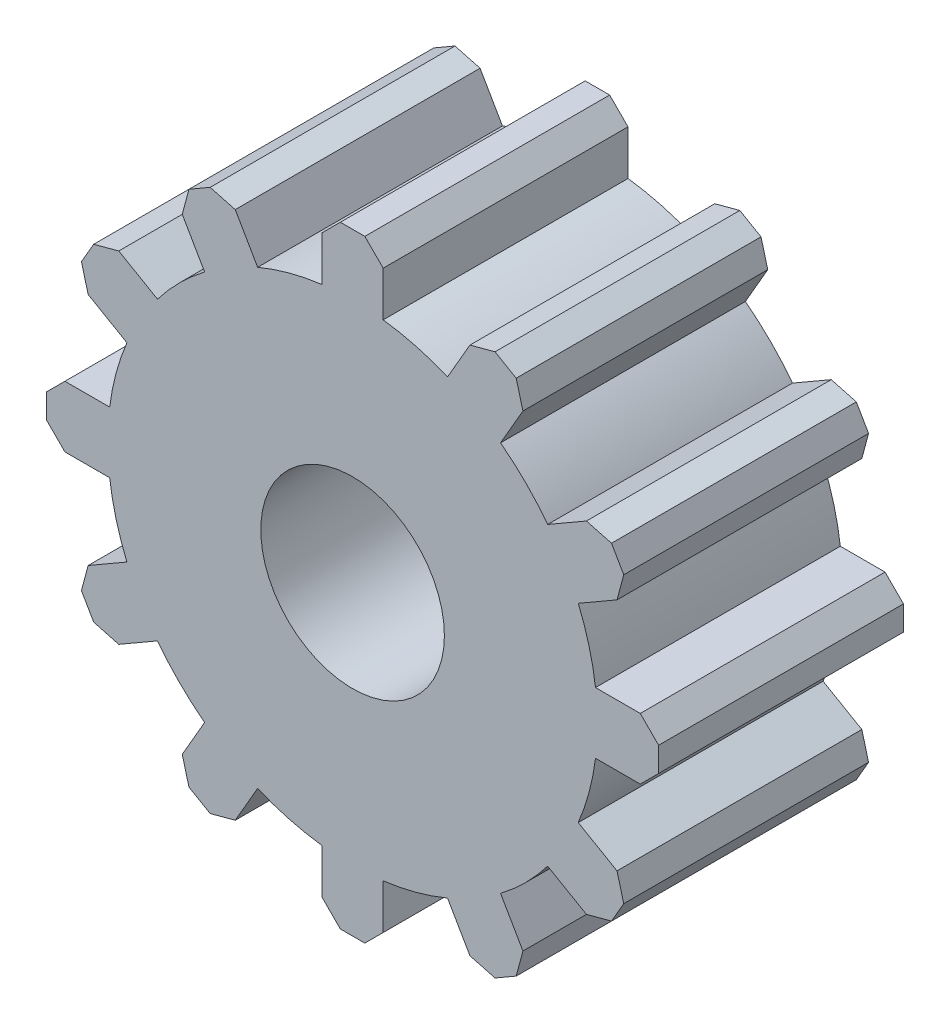
from build123d import *

# Parameters (mm, degrees)
SKETCH1_R           = 101.6
BOSS_EXTRUDE1_DEPTH = 50.8
BOSS_EXTRUDE2_DEPTH = 101.6
CHAMFER1_SIZE       = 7.62
SKETCH3_R           = 38.1
CUT_EXTRUDE1_DEPTH  = 102.6


with BuildPart() as part:
    # Sketch1 → Boss-Extrude1 (new body, symmetric)
    with BuildSketch(Plane.XY):
        Circle(SKETCH1_R)
    extrude(amount=BOSS_EXTRUDE1_DEPTH, both=True)

    # Sketch2 → Boss-Extrude2 (add, through all)
    with BuildSketch(Plane.XY.offset(50.8)):
        with BuildLine():
            Line((74.498522628, 103.635226281), (52.501477372, 116.335226281))
            Line((52.501477372, 116.335226281), (39.403039848, 93.648066989))
            ThreePointArc((39.403039848, 93.648066989), (50.8, 87.988181024), (61.400085104, 80.948066989))
            Line((61.400085104, 80.948066989), (74.498522628, 103.635226281))
        make_face()
        with BuildLine():
            Line((12.7, 100.803124952), (12.7, 127))
            Line((12.7, 127), (-12.7, 127))
            Line((-12.7, 127), (-12.7, 100.803124952))
            ThreePointArc((-12.7, 100.803124952), (0, 101.6), (12.7, 100.803124952))
        make_face()
        with BuildLine():
            Line((116.335226281, 52.501477372), (103.635226281, 74.498522628))
            Line((103.635226281, 74.498522628), (80.948066989, 61.400085104))
            ThreePointArc((80.948066989, 61.400085104), (87.988181024, 50.8), (93.648066989, 39.403039848))
            Line((93.648066989, 39.403039848), (116.335226281, 52.501477372))
        make_face()
        with BuildLine():
            Line((127, -12.7), (127, 12.7))
            Line((127, 12.7), (100.803124952, 12.7))
            ThreePointArc((100.803124952, 12.7), (101.6, 0), (100.803124952, -12.7))
            Line((100.803124952, -12.7), (127, -12.7))
        make_face()
        with BuildLine():
            Line((103.635226281, -74.498522628), (116.335226281, -52.501477372))
            Line((116.335226281, -52.501477372), (93.648066989, -39.403039848))
            ThreePointArc((93.648066989, -39.403039848), (87.988181024, -50.8), (80.948066989, -61.400085104))
            Line((80.948066989, -61.400085104), (103.635226281, -74.498522628))
        make_face()
        with BuildLine():
            Line((52.501477372, -116.335226281), (74.498522628, -103.635226281))
            Line((74.498522628, -103.635226281), (61.400085104, -80.948066989))
            ThreePointArc((61.400085104, -80.948066989), (50.8, -87.988181024), (39.403039848, -93.648066989))
            Line((39.403039848, -93.648066989), (52.501477372, -116.335226281))
        make_face()
        with BuildLine():
            Line((-12.7, -127), (12.7, -127))
            Line((12.7, -127), (12.7, -100.803124952))
            ThreePointArc((12.7, -100.803124952), (0, -101.6), (-12.7, -100.803124952))
            Line((-12.7, -100.803124952), (-12.7, -127))
        make_face()
        with BuildLine():
            Line((-74.498522628, -103.635226281), (-52.501477372, -116.335226281))
            Line((-52.501477372, -116.335226281), (-39.403039848, -93.648066989))
            ThreePointArc((-39.403039848, -93.648066989), (-50.8, -87.988181024), (-61.400085104, -80.948066989))
            Line((-61.400085104, -80.948066989), (-74.498522628, -103.635226281))
        make_face()
        with BuildLine():
            Line((-116.335226281, -52.501477372), (-103.635226281, -74.498522628))
            Line((-103.635226281, -74.498522628), (-80.948066989, -61.400085104))
            ThreePointArc((-80.948066989, -61.400085104), (-87.988181024, -50.8), (-93.648066989, -39.403039848))
            Line((-93.648066989, -39.403039848), (-116.335226281, -52.501477372))
        make_face()
        with BuildLine():
            Line((-127, 12.7), (-127, -12.7))
            Line((-127, -12.7), (-100.803124952, -12.7))
            ThreePointArc((-100.803124952, -12.7), (-101.6, 0), (-100.803124952, 12.7))
            Line((-100.803124952, 12.7), (-127, 12.7))
        make_face()
        with BuildLine():
            Line((-103.635226281, 74.498522628), (-116.335226281, 52.501477372))
            Line((-116.335226281, 52.501477372), (-93.648066989, 39.403039848))
            ThreePointArc((-93.648066989, 39.403039848), (-87.988181024, 50.8), (-80.948066989, 61.400085104))
            Line((-80.948066989, 61.400085104), (-103.635226281, 74.498522628))
        make_face()
        with BuildLine():
            Line((-52.501477372, 116.335226281), (-74.498522628, 103.635226281))
            Line((-74.498522628, 103.635226281), (-61.400085104, 80.948066989))
            ThreePointArc((-61.400085104, 80.948066989), (-50.8, 87.988181024), (-39.403039848, 93.648066989))
            Line((-39.403039848, 93.648066989), (-52.501477372, 116.335226281))
        make_face()
    extrude(amount=-BOSS_EXTRUDE2_DEPTH)

    # Chamfer1
    chamfer1_edges = [part.edges().sort_by_distance(p)[0] for p in [
        (-127, -12.7, 0),
        (-127, 12.7, 0),
        (-116.335226281, 52.501477372, 0),
        (-103.635226281, 74.498522628, 0),
        (-74.498522628, 103.635226281, 0),
        (-52.501477372, 116.335226281, 0),
        (52.501477372, 116.335226281, 0),
        (74.498522628, 103.635226281, 0),
        (103.635226281, 74.498522628, 0),
        (116.335226281, 52.501477372, 0),
        (127, 12.7, 0),
        (127, -12.7, 0),
        (116.335226281, -52.501477372, 0),
        (103.635226281, -74.498522628, 0),
        (74.498522628, -103.635226281, 0),
        (52.501477372, -116.335226281, 0),
        (12.7, -127, 0),
        (-12.7, -127, 0),
        (-12.7, 127, 0),
        (12.7, 127, 0),
        (-52.501477372, -116.335226281, 0),
        (-74.498522628, -103.635226281, 0),
        (-103.635226281, -74.498522628, 0),
        (-116.335226281, -52.501477372, 0),
    ]]
    chamfer(chamfer1_edges, length=CHAMFER1_SIZE)

    # Sketch3 → Cut-Extrude1 (cut, through all)
    with BuildSketch(Plane.XY.offset(50.8)):
        Circle(SKETCH3_R)
    extrude(amount=-CUT_EXTRUDE1_DEPTH, mode=Mode.SUBTRACT)


solid = part.part
